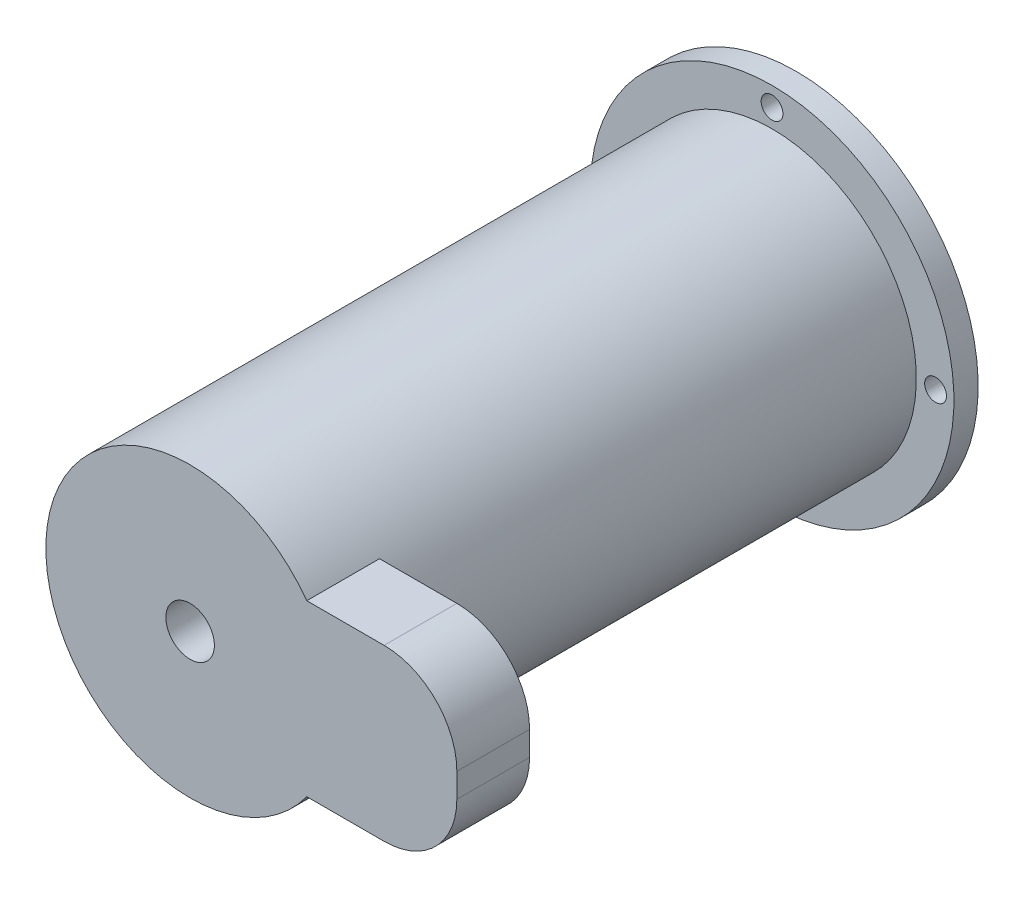
from build123d import *

# Parameters (mm, degrees)
SKETCH1_R             = 75
BOSS_EXTRUDE1_DEPTH   = 10
SKETCH2_R             = 59.5
BOSS_EXTRUDE2_DEPTH   = 240
BOSS_EXTRUDE3_DEPTH   = 30
SKETCH7_R             = 10
CUT_EXTRUDE1_DEPTH    = 30
SKETCH9_R             = 4.5
CUT_EXTRUDE3_DEPTH    = 10
BODY_MOVE_COPY1_ANGLE = 90


with BuildPart() as part:
    # Sketch1 → Boss-Extrude1 (new body)
    with BuildSketch(Plane(origin=(0, 0, 0), x_dir=(1, 0, 0), z_dir=(0, 1, 0))):
        Circle(SKETCH1_R)
    extrude(amount=BOSS_EXTRUDE1_DEPTH)

    # Sketch2 → Boss-Extrude2 (add)
    with BuildSketch(Plane(origin=(0, 10, 0), x_dir=(1, 0, 0), z_dir=(0, 1, 0))):
        Circle(SKETCH2_R)
    extrude(amount=BOSS_EXTRUDE2_DEPTH)

    # Sketch6 → Boss-Extrude3 (add)
    with BuildSketch(Plane(origin=(0, 250, 0), x_dir=(1, 0, 0), z_dir=(0, 1, 0))):
        with BuildLine():
            Line((48.117044797, 35), (80, 35))
            ThreePointArc((80, 35), (101.213203436, 26.213203436), (110, 5))
            Line((110, 5), (110, -5))
            ThreePointArc((110, -5), (101.213203436, -26.213203436), (80, -35))
            Line((80, -35), (48.117044797, -35))
            ThreePointArc((48.117044797, -35), (59.5, 0), (48.117044797, 35))
        make_face()
    extrude(amount=-BOSS_EXTRUDE3_DEPTH)

    # Sketch7 → Cut-Extrude1 (cut)
    with BuildSketch(Plane(origin=(0, 250, 0), x_dir=(1, 0, 0), z_dir=(0, 1, 0))):
        Circle(SKETCH7_R)
    extrude(amount=-CUT_EXTRUDE1_DEPTH, mode=Mode.SUBTRACT)

    # Sketch9 → Cut-Extrude3 (cut)
    with BuildSketch(Plane(origin=(0, 10, 0), x_dir=(1, 0, 0), z_dir=(0, 1, 0))):
        with Locations((0, 67.096454414)):
            Circle(SKETCH9_R)
        with Locations((-67.440146023, 0)):
            Circle(SKETCH9_R)
    cut_extrude3 = extrude(amount=-CUT_EXTRUDE3_DEPTH, mode=Mode.SUBTRACT)

    # Mirror2: Cut-Extrude3 across plane
    add(cut_extrude3.mirror(Plane.XY), mode=Mode.SUBTRACT)

    # Mirror3: Cut-Extrude3 across plane
    add(cut_extrude3.mirror(Plane(origin=(0, 0, 0), x_dir=(0, 0, 1), z_dir=(1, 0, 0))), mode=Mode.SUBTRACT)


with BuildPart() as part_1:
    # Body-Move/Copy1: moved
    add(part.part.rotate(Axis((0, 0, 0), (1, 0, 0)), BODY_MOVE_COPY1_ANGLE))


solid = part_1.part
